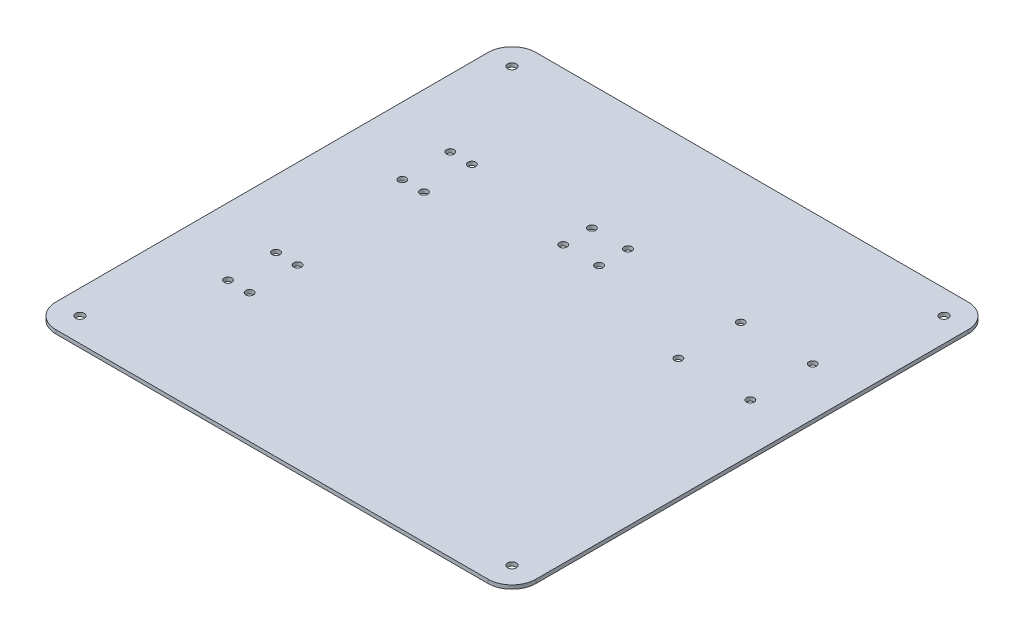
from build123d import *

# Parameters (mm, degrees)
SKETCH2_W                      = 200
SKETCH2_H                      = 200
BOSS_EXTRUDE1_DEPTH            = 1.57
F_3_6_3_6_DIAMETER_HOLE1_D     = 3.6
F_3_6_3_6_DIAMETER_HOLE1_DEPTH = 3.2
F_3_6_3_6_DIAMETER_HOLE1_TIP   = 1.081549114
F_3_2_3_2_DIAMETER_HOLE1_D     = 3.2
F_3_2_3_2_DIAMETER_HOLE1_DEPTH = 1.57
F_3_2_3_2_DIAMETER_HOLE1_TIP   = 0.96137699
FILLET1_R                      = 10
FILLET2_R                      = 10


with BuildPart() as part:
    # Sketch2 → Boss-Extrude1 (new body)
    with BuildSketch(Plane(origin=(0, 0, 0), x_dir=(1, 0, 0), z_dir=(0, 1, 0))):
        Rectangle(SKETCH2_W, SKETCH2_H)
    extrude(amount=BOSS_EXTRUDE1_DEPTH)

    # Ø3.6 (3.6) Diameter Hole1
    with Locations(Plane(origin=(0, 1.57, 0), x_dir=(1, 0, 0), z_dir=(0, 1, 0))):
        with Locations((-90, 90), (90, 90), (90, -90), (-90, -90)):
            Hole(F_3_6_3_6_DIAMETER_HOLE1_D / 2, depth=F_3_6_3_6_DIAMETER_HOLE1_DEPTH)
            with Locations((0, 0, -(F_3_6_3_6_DIAMETER_HOLE1_DEPTH + F_3_6_3_6_DIAMETER_HOLE1_TIP / 2))):  # 118° drill point
                Cone(0, F_3_6_3_6_DIAMETER_HOLE1_D / 2, F_3_6_3_6_DIAMETER_HOLE1_TIP, mode=Mode.SUBTRACT)

    # Ø3.2 (3.2) Diameter Hole1
    with Locations(Plane(origin=(0, 0, 0), x_dir=(-1, 0, 0), z_dir=(0, -1, 0))):
        with Locations((15, 48.3), (0, 48.3), (0, 36.3), (15, 36.3), (63, 46.3), (72, 46.3), (63, 26.3), (72, 26.3), (-50, 45.3), (-79.983681894, 45.3), (-79.983681894, 19.3), (-50, 19.3), (72, -26.3), (63, -26.3), (63, -46.3), (72, -46.3)):
            Hole(F_3_2_3_2_DIAMETER_HOLE1_D / 2, depth=F_3_2_3_2_DIAMETER_HOLE1_DEPTH)
            with Locations((0, 0, -(F_3_2_3_2_DIAMETER_HOLE1_DEPTH + F_3_2_3_2_DIAMETER_HOLE1_TIP / 2))):  # 118° drill point
                Cone(0, F_3_2_3_2_DIAMETER_HOLE1_D / 2, F_3_2_3_2_DIAMETER_HOLE1_TIP, mode=Mode.SUBTRACT)

    # Fillet1
    fillet1_edges = [part.edges().sort_by_distance(p)[0] for p in [
        (100, 0.785, 100),
    ]]
    fillet(fillet1_edges, radius=FILLET1_R)

    # Fillet2
    fillet2_edges = [part.edges().sort_by_distance(p)[0] for p in [
        (-100, 0.785, 100),
        (-100, 0.785, -100),
        (100, 0.785, -100),
    ]]
    fillet(fillet2_edges, radius=FILLET2_R)


solid = part.part
